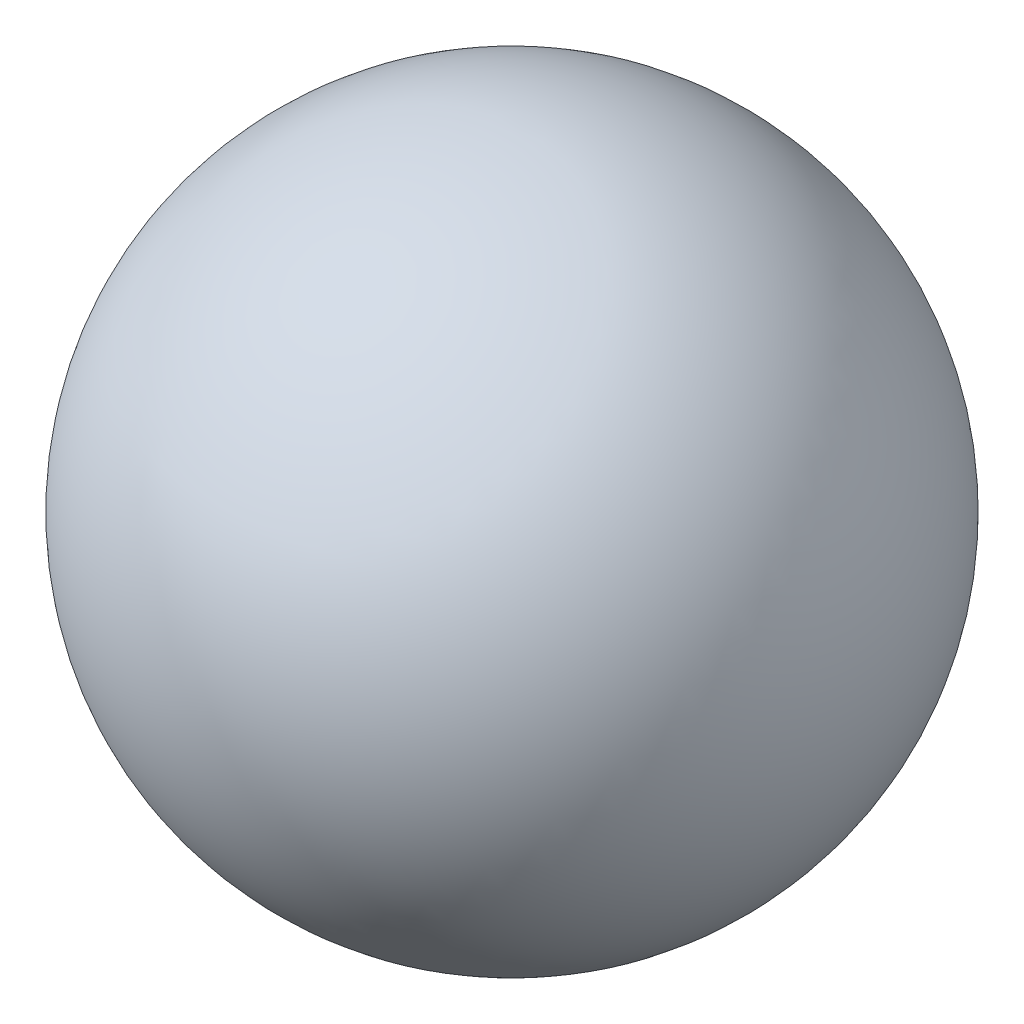
from build123d import *


with BuildPart() as part:
    # Sketch1 → Revolve4 (revolve)
    with BuildSketch(Plane(origin=(0, 0, 0), x_dir=(0, 0, -1), z_dir=(1, 0, 0))):
        with BuildLine():
            Line((0, 21.5), (0, -21.5))
            ThreePointArc((0, -21.5), (-21.5, 0), (0, 21.5))
        make_face()
    revolve(axis=Axis((0, 0, 0), (0, -1, 0)))


solid = part.part
